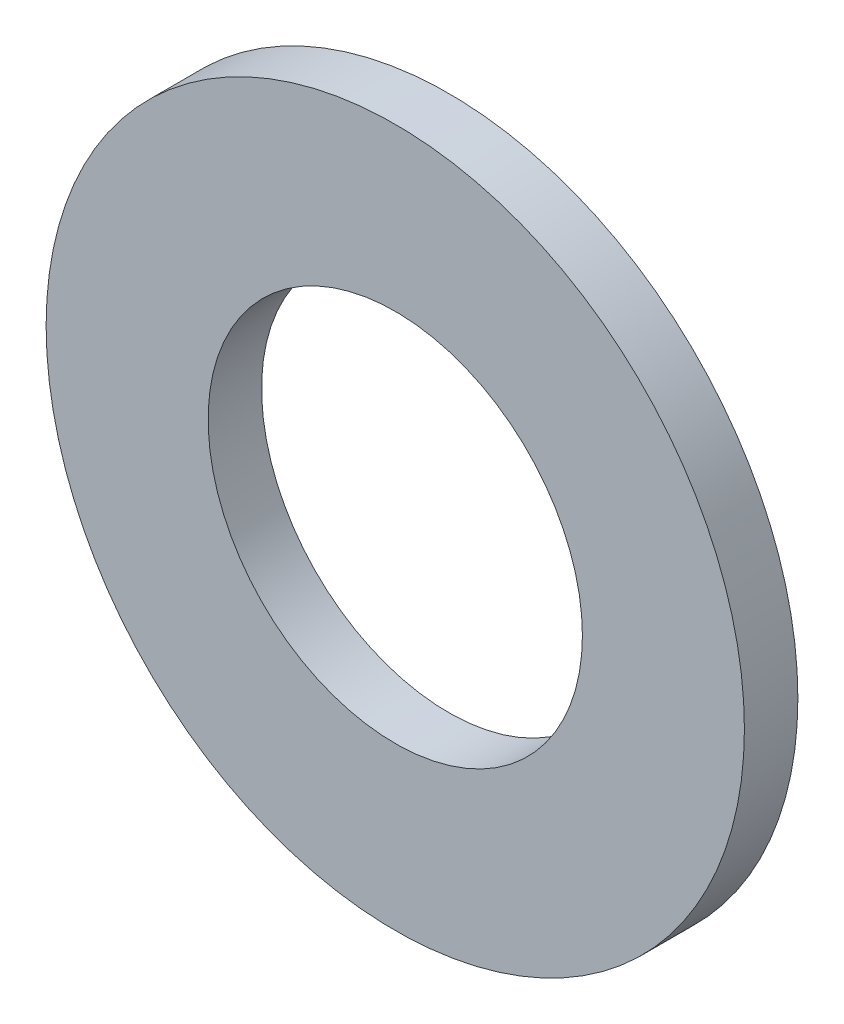
from build123d import *

# Parameters (mm, degrees)
SKETCH1_R          = 22.225
SKETCH1_R_2        = 11.9126
BASE_EXTRUDE_DEPTH = 3.4036


with BuildPart() as part:
    # Sketch1 → Base-Extrude (new body)
    with BuildSketch(Plane.XY):
        Circle(SKETCH1_R)
        Circle(SKETCH1_R_2, mode=Mode.SUBTRACT)
    extrude(amount=BASE_EXTRUDE_DEPTH)


solid = part.part
